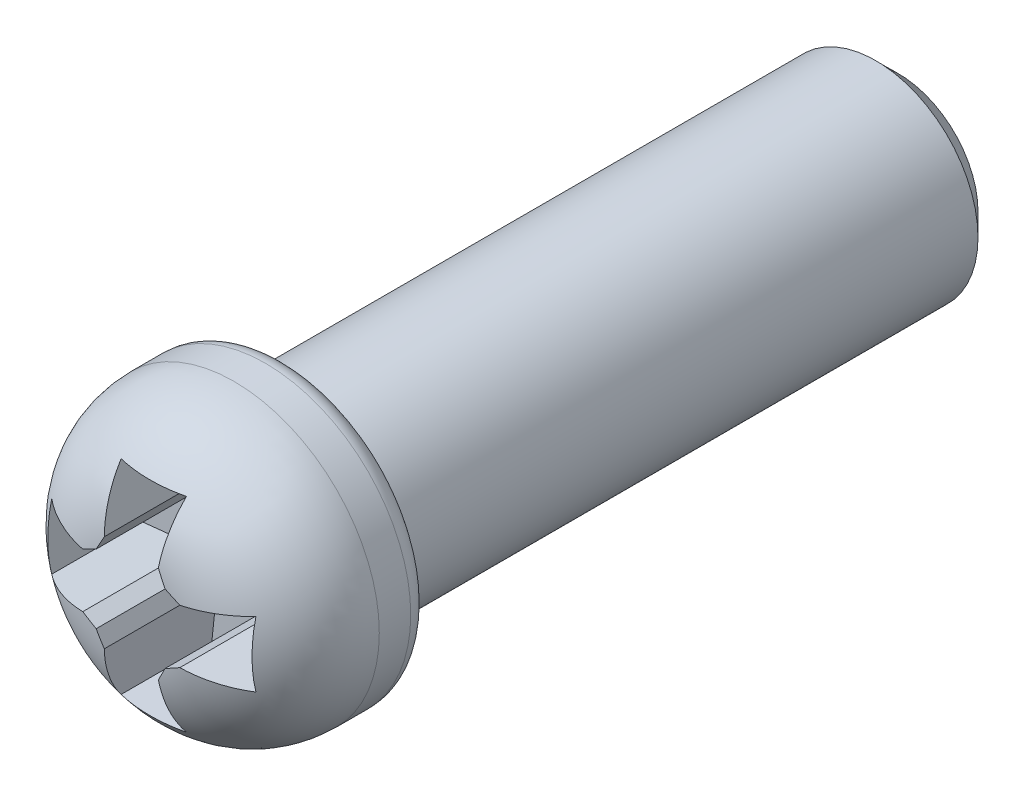
from build123d import *

# Parameters (mm, degrees)
CUT_EXTRUDE1_DEPTH = 1.524


with BuildPart() as part:
    # Sketch1 → Revolve1 (revolve)
    with BuildSketch(Plane(origin=(0, 0, 0), x_dir=(0, 0, -1), z_dir=(1, 0, 0))):
        with BuildLine():
            Line((-1.905, 0), (-1.905, 0.508))
            ThreePointArc((-1.905, 0.508), (-1.533025612, 1.406025612), (-0.635, 1.778))
            Line((-0.635, 1.778), (-0.250000008, 1.778))
            ThreePointArc((-0.250000008, 1.778), (-0.073223307, 1.704776693), (0, 1.527999992))
            Line((0, 1.527999992), (0, 1.25))
            Line((0, 1.25), (7.224, 1.25))
            Line((7.224, 1.25), (7.5, 0.974))
            Line((7.5, 0.974), (7.5, 0))
            Line((7.5, 0), (-1.905, 0))
        make_face()
    revolve(axis=Axis((0, 0, -7.5), (0, 0, 1)))

    # Sketch2 → Cut-Extrude1 (cut)
    with BuildSketch(Plane.XY.offset(0.508)):
        Polygon((-1.25000004, 0.399999962), (-1.25000004, -0.399999962), (-0.594105965, -0.331062717), (-0.421980421, -0.421980421), (-0.331062717, -0.594105965), (-0.399999962, -1.25000004), (0.399999962, -1.25000004), (0.331062717, -0.594105965), (0.421980421, -0.421980421), (0.594105965, -0.331062717), (1.25000004, -0.399999962), (1.25000004, 0.399999962), (0.594105965, 0.331062717), (0.421980421, 0.421980421), (0.331062717, 0.594105965), (0.399999962, 1.25000004), (-0.399999962, 1.25000004), (-0.331062717, 0.594105965), (-0.421980421, 0.421980421), (-0.594105965, 0.331062717), align=None)
    extrude(amount=CUT_EXTRUDE1_DEPTH, mode=Mode.SUBTRACT)


solid = part.part
